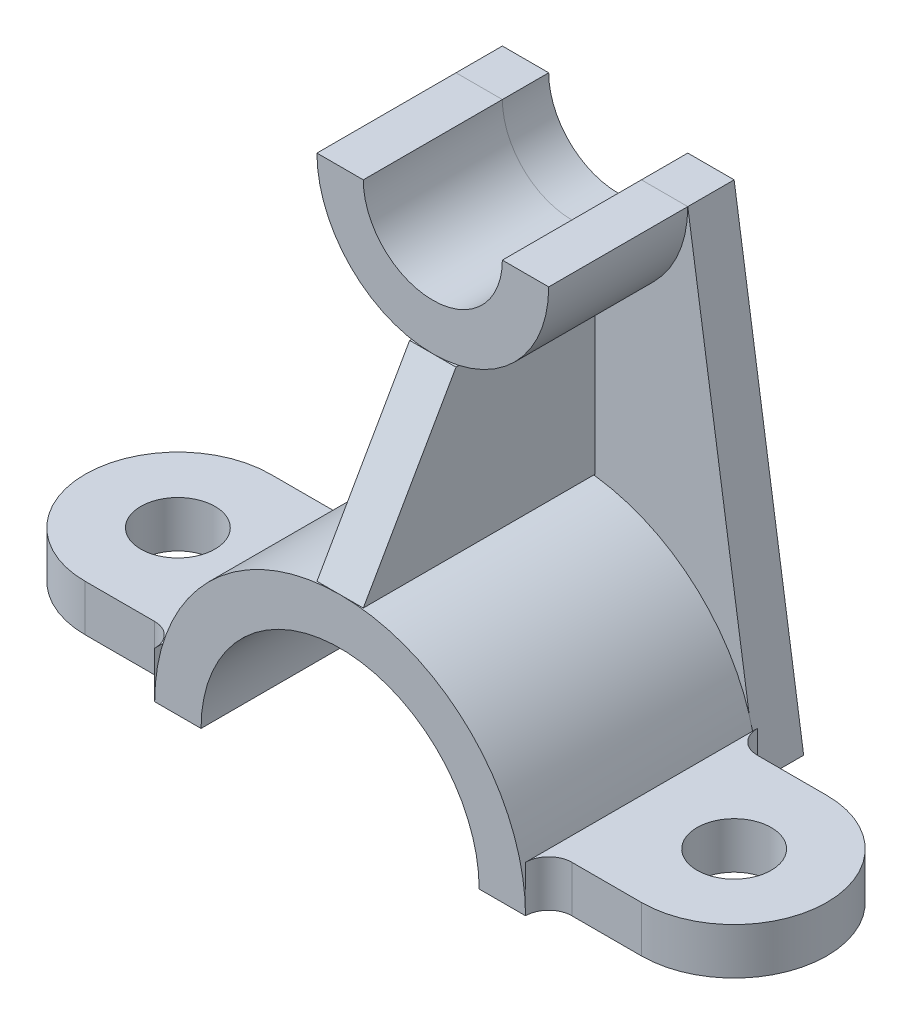
from build123d import *

# Parameters (mm, degrees)
BOSS_EXTRUDE1_DEPTH = 50
BOSS_EXTRUDE2_DEPTH = 5
BOSS_EXTRUDE3_DEPTH = 30
BOSS_EXTRUDE5_DEPTH = 10
SKETCH6_R           = 8
BOSS_EXTRUDE9_DEPTH = 10


with BuildPart() as part:
    # Sketch1 → Boss-Extrude1 (new body)
    with BuildSketch(Plane.XY):
        with BuildLine():
            Line((-40, 0), (-30, 0))
            ThreePointArc((-30, 0), (0, 30), (30, 0))
            Line((30, 0), (40, 0))
            ThreePointArc((40, 0), (0, 40), (-40, 0))
        make_face()
    extrude(amount=-BOSS_EXTRUDE1_DEPTH)



with BuildPart() as body_2:
    # Sketch2 → Boss-Extrude2 (new body, symmetric)
    with BuildSketch(Plane(origin=(0, 0, 0), x_dir=(0, 0, -1), z_dir=(1, 0, 0))):
        Polygon((0, 40), (20, 75), (50, 75), (50, 40), align=None)
    extrude(amount=BOSS_EXTRUDE2_DEPTH, both=True)


with BuildPart() as body_3:
    # Sketch4 → Boss-Extrude3 (new body)
    with BuildSketch(Plane(origin=(0, 0, -20), x_dir=(-1, 0, 0), z_dir=(0, 0, -1))):
        with BuildLine():
            Line((-15, 100), (-25, 100))
            ThreePointArc((-25, 100), (0, 75), (25, 100))
            Line((25, 100), (15, 100))
            ThreePointArc((15, 100), (0, 85), (-15, 100))
        make_face()
    extrude(amount=BOSS_EXTRUDE3_DEPTH)


with BuildPart() as body_4:
    # Sketch5 → Boss-Extrude5 (new body)
    with BuildSketch(Plane.XY.offset(-50)):
        with BuildLine():
            Line((-25, 100), (-40, 0))
            Line((-40, 0), (-30, 0))
            ThreePointArc((-30, 0), (0, 30), (30, 0))
            Line((30, 0), (40, 0))
            Line((40, 0), (25, 100))
            Line((25, 100), (15, 100))
            ThreePointArc((15, 100), (0, 85), (-15, 100))
            Line((-15, 100), (-25, 100))
        make_face()
    extrude(amount=-BOSS_EXTRUDE5_DEPTH)


with BuildPart() as part_1:
    add(part.part)

    add(body_4.part)  # Boss-Extrude9 merges body 4
    # Sketch6 → Boss-Extrude9 (add)
    with BuildSketch(Plane(origin=(0, 0, 0), x_dir=(1, 0, 0), z_dir=(0, 1, 0))):
        with BuildLine():
            Line((60, 45), (45, 45))
            ThreePointArc((45, 45), (41.464466094, 46.464466094), (40, 50))
            Line((40, 50), (40, 0))
            ThreePointArc((40, 0), (41.464466094, 3.535533906), (45, 5))
            Line((45, 5), (60, 5))
            ThreePointArc((60, 5), (80, 25), (60, 45))
        make_face()
        with Locations(Location((60, 25, 0), (0, 0, 270))):  # turned: the seam where the file's is
            Circle(SKETCH6_R, mode=Mode.SUBTRACT)
    extrude(amount=BOSS_EXTRUDE9_DEPTH)

    # Mirror3: part across plane


with BuildPart() as part_2:
    add(part_1.part)
    add(part_1.part.mirror(Plane(origin=(0, 0, 0), x_dir=(0, 0, 1), z_dir=(1, 0, 0))))


solid = Compound([body_2.part, body_3.part, part_2.part])
